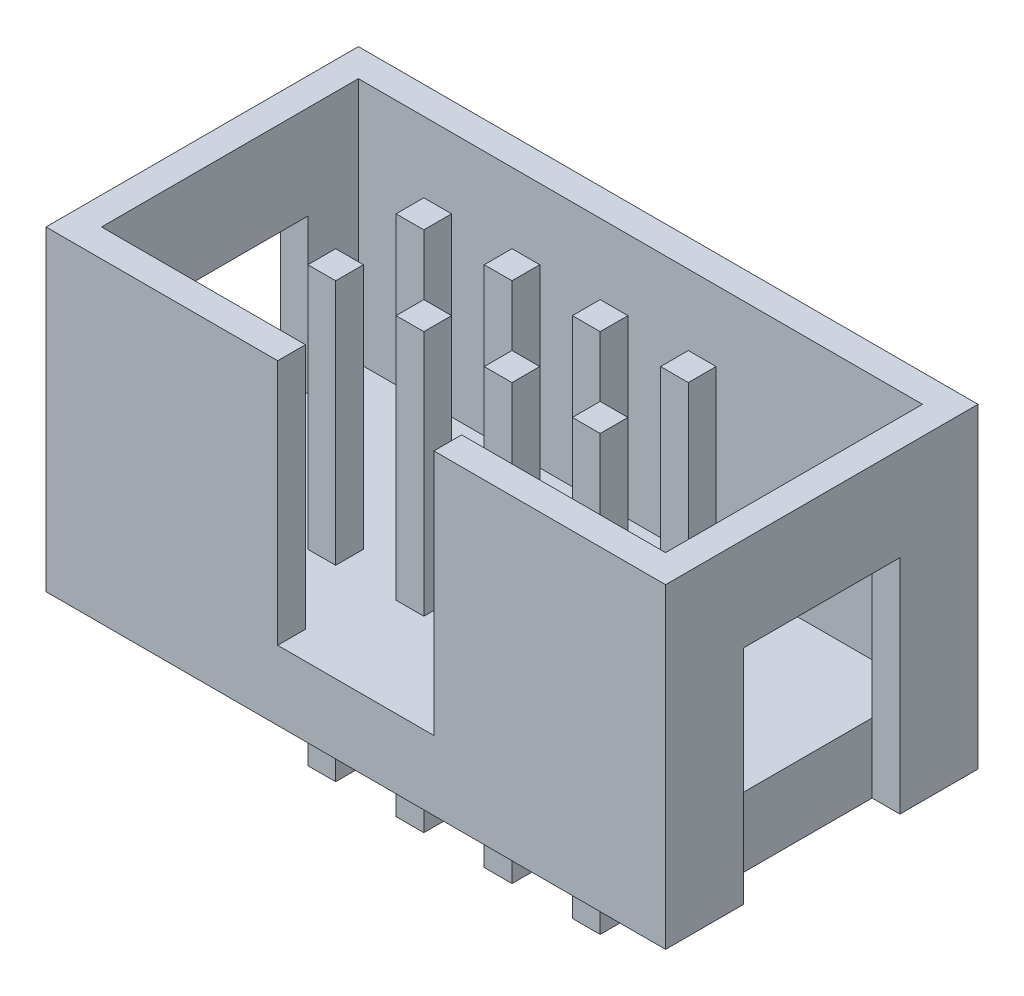
from build123d import *

# Parameters (mm, degrees)
SKETCH1_W           = 17.85
SKETCH1_H           = 9
BOSS_EXTRUDE1_DEPTH = 9.1
SKETCH2_W           = 16.25
SKETCH2_H           = 7.4
CUT_EXTRUDE1_DEPTH  = 7.1
SKETCH2_3_W         = 0.8
SKETCH2_3_H         = 0.8
BOSS_EXTRUDE2_DEPTH = 12.5
SKETCH3_W           = 4.5
SKETCH3_H           = 7.1
CUT_EXTRUDE2_DEPTH  = 2.1
SKETCH5_W           = 4.5
SKETCH5_H           = 6.4
CUT_EXTRUDE3_DEPTH  = 0.8
SKETCH6_W           = 4.5
SKETCH6_H           = 6.4
CUT_EXTRUDE4_DEPTH  = 0.8


with BuildPart() as part:
    # Sketch1 → Boss-Extrude1 (new body)
    with BuildSketch(Plane(origin=(0, 0, 0), x_dir=(1, 0, 0), z_dir=(0, 1, 0))):
        with Locations((-28.415572658, 24.590099186)):
            Rectangle(SKETCH1_W, SKETCH1_H)
    extrude(amount=BOSS_EXTRUDE1_DEPTH)

    # Sketch2 → Cut-Extrude1 (cut)
    with BuildSketch(Plane(origin=(0, 9.1, 0), x_dir=(1, 0, 0), z_dir=(0, 1, 0))):
        with Locations((-28.415572658, 24.590099186)):
            Rectangle(SKETCH2_W, SKETCH2_H)
    extrude(amount=-CUT_EXTRUDE1_DEPTH, mode=Mode.SUBTRACT)

    # Sketch2_3 → Boss-Extrude2 (add)
    with BuildSketch(Plane(origin=(0, 9.1, 0), x_dir=(1, 0, 0), z_dir=(0, 1, 0))):
        with Locations((-29.685572658, 23.320099186)):
            Rectangle(SKETCH2_3_W, SKETCH2_3_H)
        with Locations((-27.145572658, 23.320099186)):
            Rectangle(SKETCH2_3_W, SKETCH2_3_H)
        with Locations((-24.605572658, 23.320099186)):
            Rectangle(SKETCH2_3_W, SKETCH2_3_H)
        with Locations((-27.145572658, 25.860099186)):
            Rectangle(SKETCH2_3_W, SKETCH2_3_H)
        with Locations((-24.605572658, 25.860099186)):
            Rectangle(SKETCH2_3_W, SKETCH2_3_H)
        with Locations((-29.685572658, 25.860099186)):
            Rectangle(SKETCH2_3_W, SKETCH2_3_H)
        with Locations((-32.225572658, 23.320099186)):
            Rectangle(SKETCH2_3_W, SKETCH2_3_H)
        with Locations((-32.225572658, 25.860099186)):
            Rectangle(SKETCH2_3_W, SKETCH2_3_H)
    extrude(amount=-BOSS_EXTRUDE2_DEPTH)

    # Sketch3 → Cut-Extrude2 (cut)
    with BuildSketch(Plane.XY.offset(-20.090099186)):
        with Locations((-28.415572658, 5.55)):
            Rectangle(SKETCH3_W, SKETCH3_H)
    extrude(amount=-CUT_EXTRUDE2_DEPTH, mode=Mode.SUBTRACT)

    # Sketch5 → Cut-Extrude3 (cut)
    with BuildSketch(Plane.ZY.offset(37.340572658)):
        with Locations((-24.590099186, 3.2)):
            Rectangle(SKETCH5_W, SKETCH5_H)
    extrude(amount=-CUT_EXTRUDE3_DEPTH, mode=Mode.SUBTRACT)

    # Sketch6 → Cut-Extrude4 (cut)
    with BuildSketch(Plane(origin=(-19.490572658, 0, 0), x_dir=(0, 0, -1), z_dir=(1, 0, 0))):
        with Locations((24.590099186, 3.2)):
            Rectangle(SKETCH6_W, SKETCH6_H)
    extrude(amount=-CUT_EXTRUDE4_DEPTH, mode=Mode.SUBTRACT)


solid = part.part
